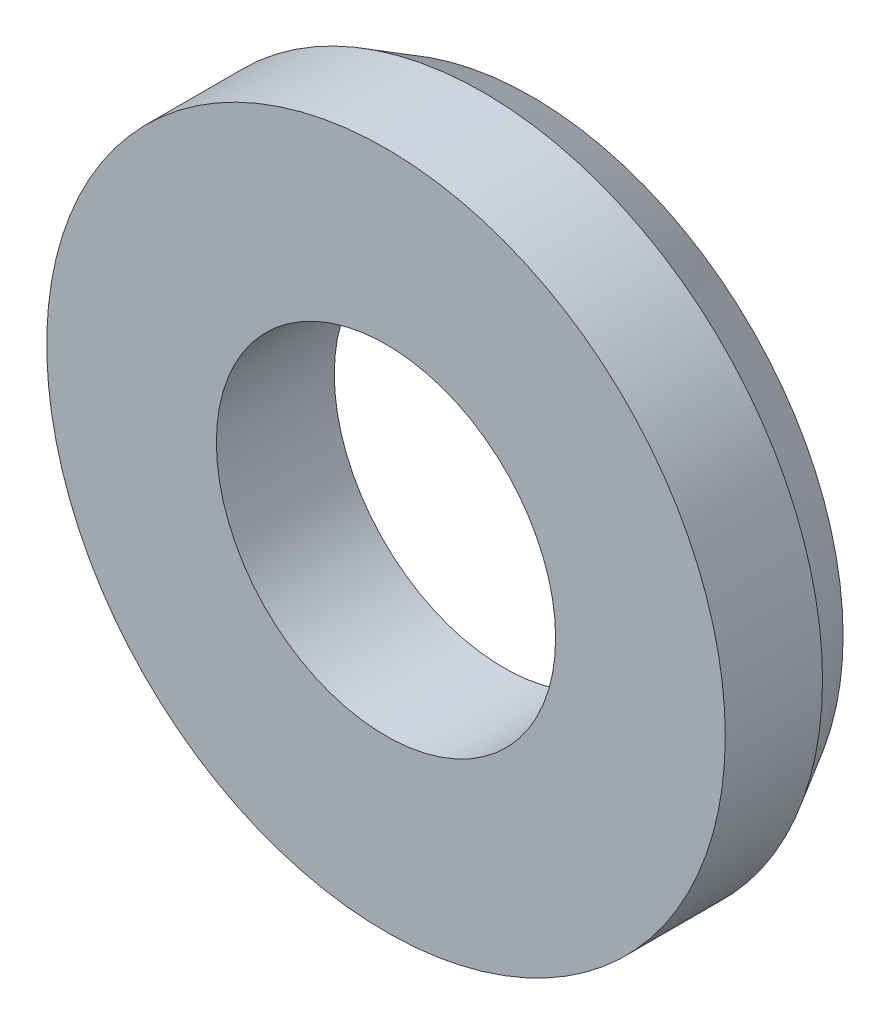
from build123d import *


with BuildPart() as part:
    # Sketch1 → Revolve1 (revolve)
    with BuildSketch(Plane(origin=(0, 0, 0), x_dir=(1, 0, 0), z_dir=(0, 1, 0))):
        with BuildLine():
            Line((0.917246461, 1.15), (0.75, 1.15))
            ThreePointArc((0.75, 1.15), (0.626357863, 1.104661345), (0.5, 1.067557949))
            Line((0.5, 1.067557949), (0.5, 0.72))
            Line((0.5, 0.72), (1, 0.72))
            Line((1, 0.72), (1, 1.006666667))
            Line((1, 1.006666667), (0.917246461, 1.15))
        make_face()
    revolve(axis=Axis((0, 0, -1.15), (0, 0, 1)))


solid = part.part
